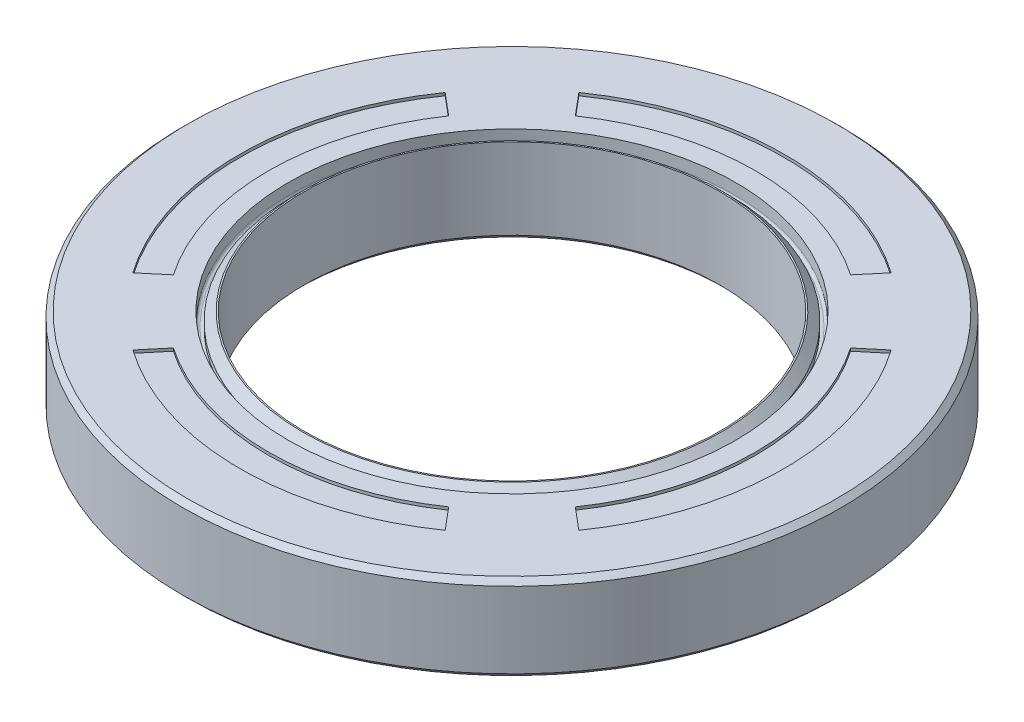
from build123d import *

# Parameters (mm, degrees)
CUT_EXTRUDE1_DEPTH = 0.2
CIRPATTERN1_COUNT  = 4


with BuildPart() as part:
    # Sketch1 → Revolve1 (revolve)
    with BuildSketch(Plane.XY):
        with BuildLine():
            ThreePointArc((15.4, 3.241206918), (15.541421356, 3.299785562), (15.6, 3.441206918))
            Line((15.6, 3.441206918), (15.6, 4.241206918))
            Line((15.6, 4.241206918), (22.646446609, 4.241206918))
            Line((22.646446609, 4.241206918), (23, 3.887653527))
            Line((23, 3.887653527), (23, -1.405239692))
            Line((23, -1.405239692), (22.646446609, -1.758793082))
            Line((22.646446609, -1.758793082), (21, -1.758793082))
            Line((21, -1.758793082), (21, 2.541206918))
            Line((21, 2.541206918), (17.5, 2.541206918))
            Line((17.5, 2.541206918), (17.5, -1.758793082))
            Line((17.5, -1.758793082), (14.853553391, -1.758793082))
            Line((14.853553391, -1.758793082), (14.5, -1.405239692))
            Line((14.5, -1.405239692), (14.5, 3.887653527))
            Line((14.5, 3.887653527), (14.5, 4.241206918))
            Line((14.5, 4.241206918), (14.6, 4.241206918))
            Line((14.6, 4.241206918), (15.2, 3.641206918))
            Line((15.2, 3.641206918), (15.2, 3.241206918))
            Line((15.2, 3.241206918), (15.4, 3.241206918))
        make_face()
    revolve(axis=Axis((0, 10.772096588, 0), (0, -1, 0)))

    # Sketch2 → Cut-Extrude1 (cut)
    with BuildSketch(Plane(origin=(0, 4.241206918, 0), x_dir=(1, 0, 0), z_dir=(0, 1, 0))):
        with BuildLine():
            Line((-14.025254522, -9.606884801), (-15.563888841, -10.897952291))
            ThreePointArc((-15.563888841, -10.897952291), (-19, 0), (-15.563888841, 10.897952291))
            Line((-15.563888841, 10.897952291), (-14.025254522, 9.606884801))
            ThreePointArc((-14.025254522, 9.606884801), (-17, 0), (-14.025254522, -9.606884801))
        make_face()
    cut_extrude1 = extrude(amount=-CUT_EXTRUDE1_DEPTH, mode=Mode.SUBTRACT)

    # CirPattern1: Cut-Extrude1 ×4 about axis
    cirpattern1_axis = Axis((0, 0, 0), (0, 1, 0))
    for i in range(1, CIRPATTERN1_COUNT):
        add(cut_extrude1.rotate(cirpattern1_axis, i * 360 / CIRPATTERN1_COUNT), mode=Mode.SUBTRACT)


solid = part.part
